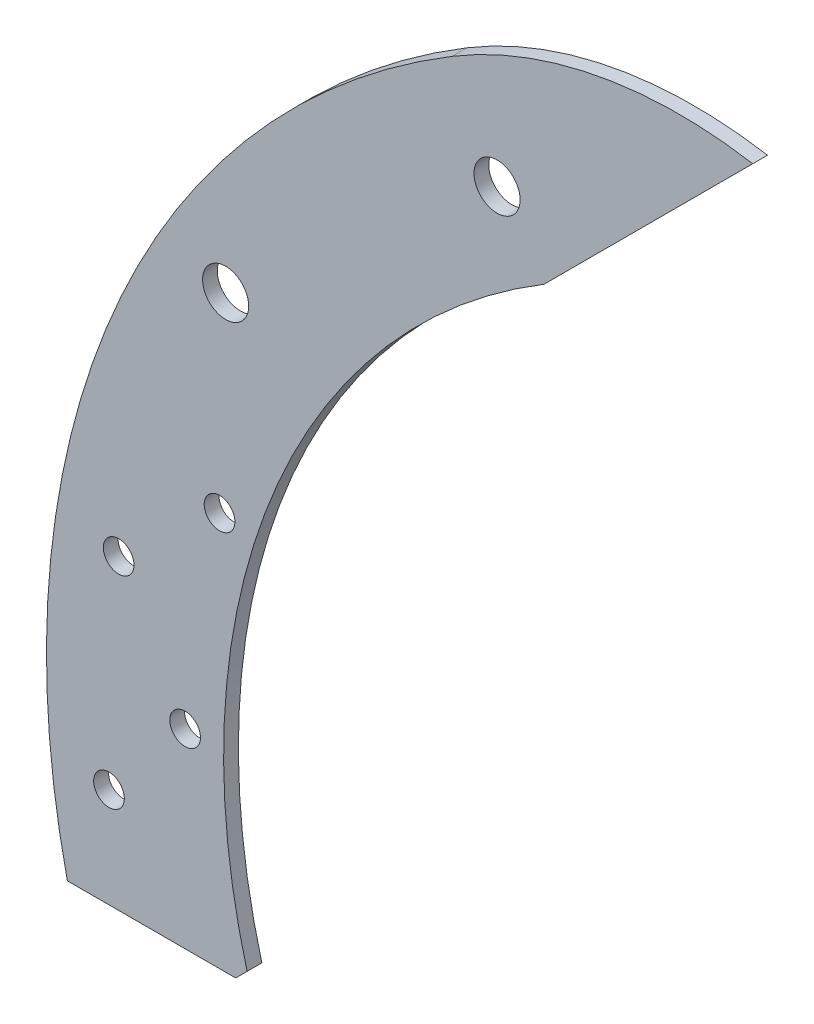
from build123d import *

# Parameters (mm, degrees)
BOSS_EXTRUDE1_DEPTH              = 3.175
SKETCH2_R                        = 3.302
CUT_EXTRUDE1_DEPTH               = 3.175
SKETCH4_R                        = 3.302
CUT_EXTRUDE2_DEPTH               = 3.175
F_25_64_0_39063_DIAMETER_HOLE1_D = 9.922002


with BuildPart() as part:
    # Sketch1 → Boss-Extrude1 (new body)
    with BuildSketch(Plane.XY):
        with BuildLine():
            Line((-138.956026155, -36.5125), (-175.156764378, -36.5125))
            ThreePointArc((-175.156764378, -36.5125), (-165.259458004, 74.330287718), (-92.387479089, 158.435905553))
            ThreePointArc((-92.387479089, 158.435905553), (-61.178796261, 170.407509665), (-27.754441861, 170.74473641))
            Line((-27.754441861, 170.74473641), (-72.655722467, 125.843455804))
            ThreePointArc((-72.655722467, 125.843455804), (-131.365317745, 56.585646012), (-136.505752305, -34.06222615))
            Line((-136.505752305, -34.06222615), (-138.956026155, -36.5125))
        make_face()
    extrude(amount=BOSS_EXTRUDE1_DEPTH)

    # Sketch2 → Cut-Extrude1 (cut)
    with BuildSketch(Plane.XY.offset(3.175)):
        with Locations((-142.427155303, 48.347866959)):
            Circle(SKETCH2_R)
        with Locations((-149.837364131, 4.445)):
            Circle(SKETCH2_R)
    extrude(amount=-CUT_EXTRUDE1_DEPTH, mode=Mode.SUBTRACT)

    # Sketch4 → Cut-Extrude2 (cut)
    with BuildSketch(Plane.XY.offset(3.175)):
        with Locations((-164.125827505, 29.433503815)):
            Circle(SKETCH4_R)
        with Locations((-166.205357894, -15.073647178)):
            Circle(SKETCH4_R)
    extrude(amount=-CUT_EXTRUDE2_DEPTH, mode=Mode.SUBTRACT)

    # 25_64 _0.39063_ Diameter Hole1 (through all)
    with Locations(Plane.XY.offset(3.175)):
        with Locations((-82.747055002, 138.99473641), (-141.119641567, 90.014320551)):
            Hole(F_25_64_0_39063_DIAMETER_HOLE1_D / 2)


solid = part.part
